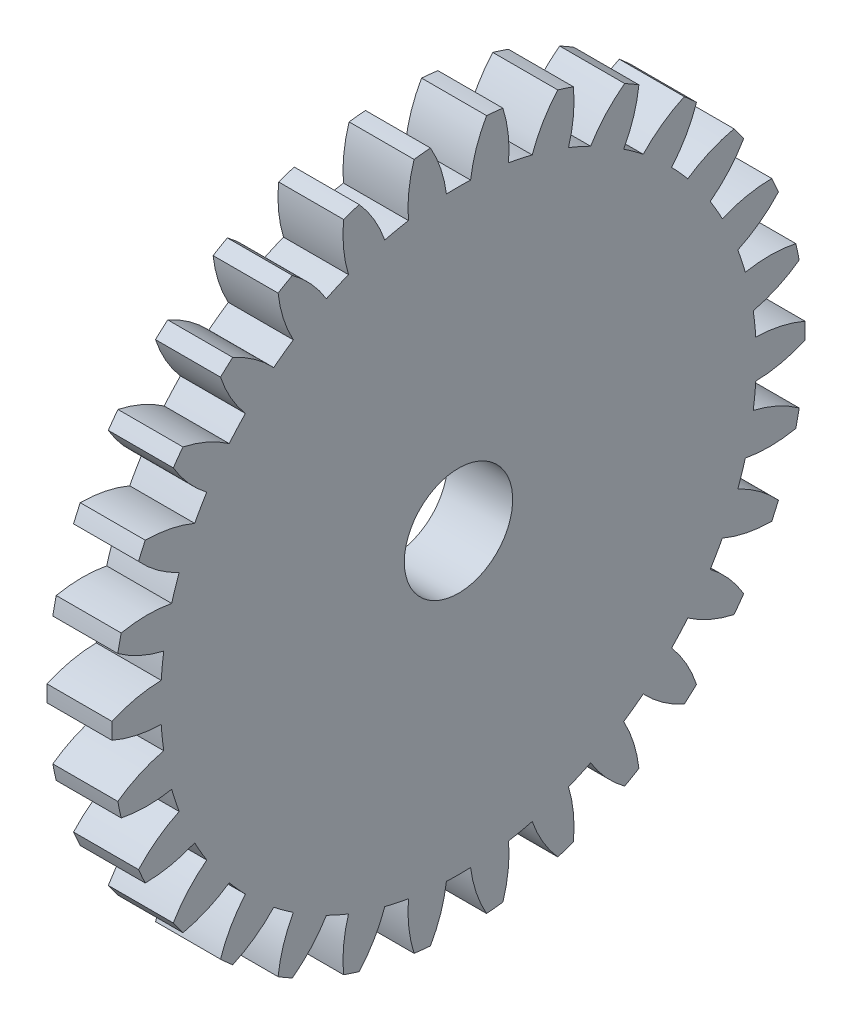
from build123d import *

# Parameters (mm, degrees)
BASPROSKE_W     = 3
BASPROSKE_H     = 16
TOOTHCUT_DEPTH  = 23.825424421
TEETHCUTS_COUNT = 30
TEETHCUTS_ANGLE = 348
BORSKE_R        = 2.5
BORE_DEPTH      = 50.0000508


with BuildPart() as part:
    # BasProSke → Base-Revolve (revolve)
    with BuildSketch(Plane(origin=(0, 0, 0), x_dir=(1, 0, 0), z_dir=(0, 1, 0)), mode=Mode.PRIVATE) as base_revolve_sk:
        with Locations((1.5, 8)):
            Rectangle(BASPROSKE_W, BASPROSKE_H)
    revolve(base_revolve_sk.sketch.rotate(Axis((-10, 0, 0), (1, 0, 0)), 180), axis=Axis((-10, 0, 0), (1, 0, 0)))

    # TooCutSke → ToothCut (cut, through all)
    with BuildSketch(Plane(origin=(0, 0, 0), x_dir=(0, 0, -1), z_dir=(1, 0, 0))):
        with BuildLine():
            ThreePointArc((0.558154026, 13.737665926), (0, 13.749), (-0.558154026, 13.737665926))
            ThreePointArc((-0.558154026, 13.737665926), (-0.82267139, 14.891986419), (-1.308756454, 15.971869074))
            ThreePointArc((-1.308756454, 15.971869074), (0, 16.0254), (1.308756454, 15.971869074))
            ThreePointArc((1.308756454, 15.971869074), (0.82267139, 14.891986419), (0.558154026, 13.737665926))
        make_face()
    toothcut = extrude(amount=TOOTHCUT_DEPTH, mode=Mode.SUBTRACT)

    # TeethCuts: ToothCut ×30 about axis
    teethcuts_axis = Axis((-10, 0, 0), (1, 0, 0))
    for i in range(1, TEETHCUTS_COUNT):
        add(toothcut.rotate(teethcuts_axis, i * TEETHCUTS_ANGLE / (TEETHCUTS_COUNT - 1)), mode=Mode.SUBTRACT)

    # BorSke → Bore (cut, symmetric)
    with BuildSketch(Plane(origin=(0, 0, 0), x_dir=(0, 0, -1), z_dir=(1, 0, 0))):
        with Locations(Location((0, 0, 0), (0, 0, 180))):
            Circle(BORSKE_R)
    extrude(amount=BORE_DEPTH, both=True, mode=Mode.SUBTRACT)


solid = part.part
